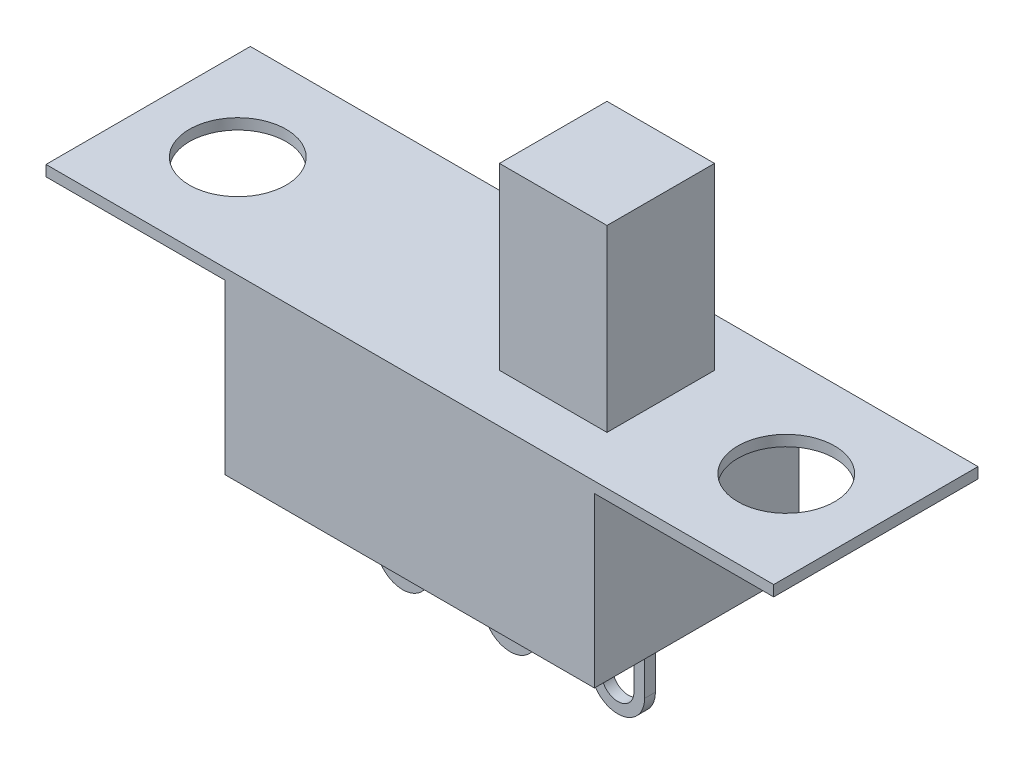
from build123d import *

# Parameters (mm, degrees)
SKETCH1_W           = 10.3
SKETCH1_H           = 5
BOSS_EXTRUDE1_DEPTH = 2.85
SKETCH2_W           = 5.7
SKETCH2_H           = 0.3
BOSS_EXTRUDE2_DEPTH = 5
SKETCH3_R           = 1.35
CUT_EXTRUDE1_DEPTH  = 5
SKETCH4_W           = 3
SKETCH4_H           = 3
BOSS_EXTRUDE3_DEPTH = 5
BOSS_EXTRUDE4_DEPTH = 0.15
LPATTERN1_COUNT     = 3
LPATTERN1_PITCH     = 3


with BuildPart() as part:
    # Sketch1 → Boss-Extrude1 (new body, symmetric)
    with BuildSketch(Plane.XY):
        Rectangle(SKETCH1_W, SKETCH1_H)
    extrude(amount=BOSS_EXTRUDE1_DEPTH, both=True)

    # Sketch2 → Boss-Extrude2 (add)
    with BuildSketch(Plane(origin=(5.15, 0, 0), x_dir=(0, 0, -1), z_dir=(1, 0, 0))):
        with Locations((0, 2.35)):
            Rectangle(SKETCH2_W, SKETCH2_H)
    boss_extrude2 = extrude(amount=BOSS_EXTRUDE2_DEPTH)

    # Sketch3 → Cut-Extrude1 (cut)
    with BuildSketch(Plane(origin=(0, 2.5, 0), x_dir=(1, 0, 0), z_dir=(0, 1, 0))):
        with Locations((7.65, 0)):
            Circle(SKETCH3_R)
    cut_extrude1 = extrude(amount=-CUT_EXTRUDE1_DEPTH, mode=Mode.SUBTRACT)

    # Mirror1: Boss-Extrude2, Cut-Extrude1 across plane
    add(boss_extrude2.mirror(Plane(origin=(0, 0, 0), x_dir=(0, 0, 1), z_dir=(1, 0, 0))))
    add(cut_extrude1.mirror(Plane(origin=(0, 0, 0), x_dir=(0, 0, 1), z_dir=(1, 0, 0))), mode=Mode.SUBTRACT)

    # Sketch4 → Boss-Extrude3 (add)
    with BuildSketch(Plane(origin=(0, 2.5, 0), x_dir=(1, 0, 0), z_dir=(0, 1, 0))):
        with Locations((2.65, 0)):
            Rectangle(SKETCH4_W, SKETCH4_H)
    extrude(amount=BOSS_EXTRUDE3_DEPTH)

    # Sketch5 → Boss-Extrude4 (add, symmetric)
    with BuildSketch(Plane.XY):
        with BuildLine():
            Line((-3.65, -2.5), (-2.15, -2.5))
            Line((-2.15, -2.5), (-2.15, -4.75))
            ThreePointArc((-2.15, -4.75), (-2.9, -5.5), (-3.65, -4.75))
            Line((-3.65, -4.75), (-3.65, -2.5))
        make_face()
        with BuildLine():
            Line((-2.45, -4.15), (-2.45, -4.75))
            ThreePointArc((-2.45, -4.75), (-2.9, -5.2), (-3.35, -4.75))
            Line((-3.35, -4.75), (-3.35, -4.15))
            ThreePointArc((-3.35, -4.15), (-2.9, -3.7), (-2.45, -4.15))
        make_face(mode=Mode.SUBTRACT)
    boss_extrude4 = extrude(amount=BOSS_EXTRUDE4_DEPTH, both=True)

    # LPattern1: Boss-Extrude4 ×3
    with Locations(*[(i * LPATTERN1_PITCH, 0, 0) for i in range(1, LPATTERN1_COUNT)]):
        add(boss_extrude4)


solid = part.part
